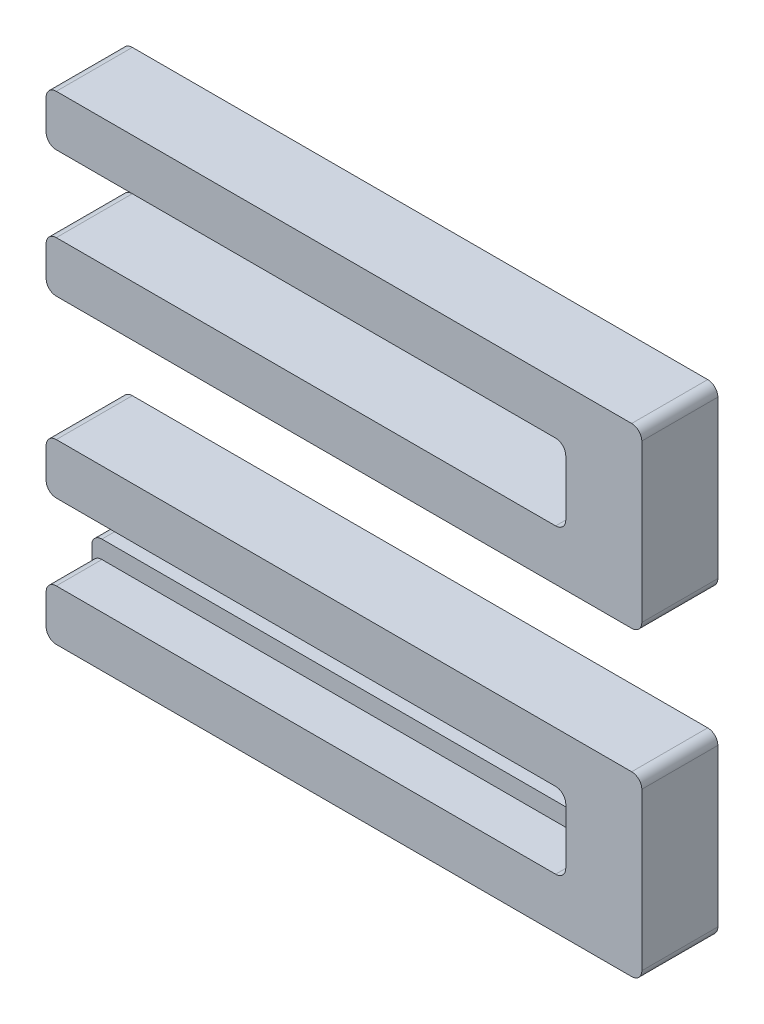
from build123d import *

# Parameters (mm, degrees)
BOSS_EXTRUDE1_DEPTH   = 3
BOSS_EXTRUDE1_2_DEPTH = 3
SKETCH2_4_W           = 20.5
SKETCH2_4_H           = 0.7
BOSS_EXTRUDE3_DEPTH   = 1.2
FILLET2_R             = 0.4
FILLET3_R             = 0.4


with BuildPart() as part:
    # Sketch2 → Boss-Extrude1 (new body)
    with BuildSketch(Plane.XY):
        Polygon((0, 2), (0, 0), (23.5, 0), (23.5, 7), (0, 7), (0, 5), (20.5, 5), (20.5, 2), align=None)
    extrude(amount=BOSS_EXTRUDE1_DEPTH)



with BuildPart() as body_2:
    # Sketch2 → Boss-Extrude1 2 (new body)
    with BuildSketch(Plane.XY):
        Polygon((20.5, -6.899471306), (20.5, -9.899471306), (0, -9.899471306), (0, -11.899471306), (23.5, -11.899471306), (23.5, -4.899471306), (0, -4.899471306), (0, -6.899471306), align=None)
    extrude(amount=BOSS_EXTRUDE1_2_DEPTH)


with BuildPart() as part_1:
    add(part.part)

    add(body_2.part)  # Boss-Extrude3 merges body 2
    # Sketch2_4 → Boss-Extrude3 (add)
    with BuildSketch(Plane.XY):
        with Locations((10.25, 4.65)):
            Rectangle(SKETCH2_4_W, SKETCH2_4_H)
        with Locations((10.25, -9.549471306)):
            Rectangle(SKETCH2_4_W, SKETCH2_4_H)
    extrude(amount=BOSS_EXTRUDE3_DEPTH)

    # Fillet2
    fillet2_edges = [part_1.edges().sort_by_distance(p)[0] for p in [
        (0, 5, 2.1),
        (20.5, 2, 1.5),
        (20.5, 4.3, 0.6),
        (20.5, 5, 2.1),
        (23.5, 7, 1.5),
        (23.5, 0, 1.5),
        (0, 0, 1.5),
        (0, 2, 1.5),
        (0, 4.3, 0.6),
        (0, 7, 1.5),
    ]]
    fillet(fillet2_edges, radius=FILLET2_R)

    # Fillet3
    fillet3_edges = [part_1.edges().sort_by_distance(p)[0] for p in [
        (23.5, -11.899471306, 1.5),
        (23.5, -4.899471306, 1.5),
        (20.5, -6.899471306, 1.5),
        (20.5, -9.899471306, 2.1),
        (20.5, -9.199471306, 0.6),
        (0, -11.899471306, 1.5),
        (0, -9.899471306, 2.1),
        (0, -9.199471306, 0.6),
        (0, -4.899471306, 1.5),
        (0, -6.899471306, 1.5),
    ]]
    fillet(fillet3_edges, radius=FILLET3_R)


solid = part_1.part
